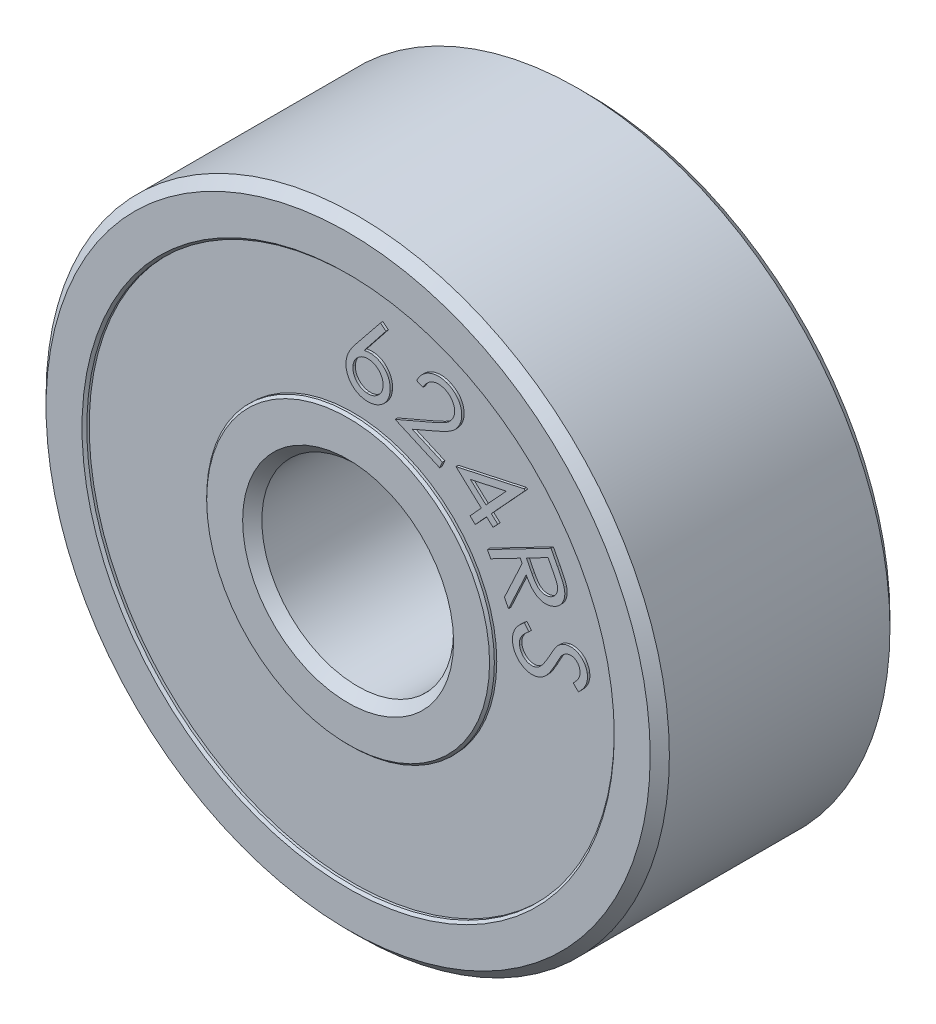
from build123d import *

# Parameters (mm, degrees)
SKETCH1_R           = 6.5
SKETCH1_R_2         = 2
BOSS_EXTRUDE1_DEPTH = 5
SKETCH2_R           = 5.5
SKETCH2_R_2         = 3
CUT_EXTRUDE1_DEPTH  = 0.1
CUT_EXTRUDE2_START  = -4.9
SKETCH2_2_R         = 5.5
SKETCH2_2_R_2       = 3
CUT_EXTRUDE2_DEPTH  = 0.1
CHAMFER1_SIZE       = 0.2
CHAMFER2_SIZE       = 0.05
BOSS_EXTRUDE2_DEPTH = 0.05
BOSS_EXTRUDE3_DEPTH = 0.05


with BuildPart() as part:
    # Sketch1 → Boss-Extrude1 (new body)
    with BuildSketch(Plane.XY):
        Circle(SKETCH1_R)
        Circle(SKETCH1_R_2, mode=Mode.SUBTRACT)
    extrude(amount=BOSS_EXTRUDE1_DEPTH)

    # Sketch2 → Cut-Extrude1 (cut)
    with BuildSketch(Plane.XY.offset(5)):
        Circle(SKETCH2_R)
        Circle(SKETCH2_R_2, mode=Mode.SUBTRACT)
    extrude(amount=-CUT_EXTRUDE1_DEPTH, mode=Mode.SUBTRACT)

    # Sketch2_2 → Cut-Extrude2 (cut)
    with BuildSketch(Plane.XY.offset(5).offset(CUT_EXTRUDE2_START)):
        Circle(SKETCH2_2_R)
        Circle(SKETCH2_2_R_2, mode=Mode.SUBTRACT)
    extrude(amount=-CUT_EXTRUDE2_DEPTH, mode=Mode.SUBTRACT)

    # Chamfer1
    chamfer1_edges = [part.edges().sort_by_distance(p)[0] for p in [
        (-2, 0, 0),
        (-2, 0, 5),
        (-6.5, 0, 5),
        (-6.5, 0, 0),
    ]]
    chamfer(chamfer1_edges, length=CHAMFER1_SIZE)

    # Chamfer2
    chamfer2_edges = [part.edges().sort_by_distance(p)[0] for p in [
        (-3, 0, 5),
        (-5.5, 0, 5),
        (-5.5, 0, 0),
        (-3, 0, 0),
    ]]
    chamfer(chamfer2_edges, length=CHAMFER2_SIZE)

    # Sketch3 → Boss-Extrude2 (add)
    # profile 1 of 5: a face of its own
    with BuildSketch(Plane(origin=(0, 0, 0.1), x_dir=(-1, 0, 0), z_dir=(0, 0, -1))):
        with BuildLine():
            Line((3.626850401, 1.037824219), (3.721802324, 0.923942007))
            add(Edge.make_bspline(
                [(3.721802324, 0.923942007), (3.704208047, 0.910028509), (3.670492204, 0.883366129), (3.626324449, 0.840217202), (3.589323839, 0.797503445), (3.560337169, 0.754296194), (3.539224488, 0.71072062), (3.525914966, 0.66695975), (3.520716042, 0.62289401), (3.523565615, 0.594005214), (3.52498742, 0.579591045)],
                knots=[0, 0, 0, 0, 1.291613416, 2.475113613, 3.551739568, 4.542488394, 5.463974027, 6.331243527, 7.167368001, 8, 8, 8, 8], degree=3))
            add(Edge.make_bspline(
                [(3.52498742, 0.579591045), (3.527274467, 0.567390948), (3.531811528, 0.543188293), (3.544150394, 0.508546185), (3.560175974, 0.475542158), (3.580479348, 0.4451073), (3.603721013, 0.41729304), (3.630069864, 0.393834227), (3.658483943, 0.374176738), (3.689267609, 0.359680955), (3.721038495, 0.349052168), (3.753486298, 0.342999974), (3.786173736, 0.341340247), (3.807754072, 0.343722843), (3.818557132, 0.344915565)],
                knots=[0, 0, 0, 0, 1.068019873, 2.118746719, 3.156924569, 4.22201185, 5.262876175, 6.271215077, 7.252568238, 8.229090771, 9.192407108, 10.131769843, 11.064768797, 12, 12, 12, 12], degree=3))
            add(Edge.make_bspline(
                [(3.818557132, 0.344915565), (3.830901192, 0.347505041), (3.855746676, 0.352717006), (3.891314688, 0.368356986), (3.925499258, 0.38991091), (3.945921844, 0.408384053), (3.956477805, 0.417932392)],
                knots=[0, 0, 0, 0, 0.95294517, 1.918038666, 2.923882512, 4, 4, 4, 4], degree=3))
            add(Edge.make_bspline(
                [(3.956477805, 0.417932392), (3.96396901, 0.42557015), (3.979715441, 0.441624635), (4.002763782, 0.46835635), (4.026262622, 0.499137625), (4.050815029, 0.533381446), (4.075608975, 0.571800714), (4.101571299, 0.613547586), (4.127990018, 0.659263107), (4.14526443, 0.691323333), (4.154194151, 0.707896334)],
                knots=[0, 0, 0, 0, 0.728914955, 1.532171184, 2.403181096, 3.367209391, 4.402740162, 5.518377551, 6.717166475, 8, 8, 8, 8], degree=3))
            add(Edge.make_bspline(
                [(4.154194151, 0.707896334), (4.163188053, 0.724333743), (4.180339931, 0.755680808), (4.205183277, 0.800326292), (4.228651377, 0.840089054), (4.250533454, 0.87506404), (4.270289635, 0.905543505), (4.288243335, 0.93124411), (4.304685043, 0.95214504), (4.315683887, 0.963966008), (4.320660497, 0.969314603)],
                knots=[0, 0, 0, 0, 1.447593943, 2.760643181, 3.947082127, 5.014218628, 5.947845825, 6.752948938, 7.435750889, 8, 8, 8, 8], degree=3))
            add(Edge.make_bspline(
                [(4.320660497, 0.969314603), (4.328342461, 0.976970428), (4.343541921, 0.992118171), (4.368296868, 1.012029814), (4.393624244, 1.030086341), (4.420082765, 1.04525028), (4.447314605, 1.058460667), (4.475594522, 1.068701873), (4.504580443, 1.077575354), (4.524536377, 1.080912491), (4.534602805, 1.082595853)],
                knots=[0, 0, 0, 0, 1.055305512, 2.088017491, 3.089115952, 4.081051721, 5.053816907, 6.032042178, 7.007297443, 8, 8, 8, 8], degree=3))
            add(Edge.make_bspline(
                [(4.534602805, 1.082595853), (4.550402757, 1.084550351), (4.581644836, 1.088415083), (4.628484312, 1.086279171), (4.674049258, 1.078488802), (4.717906567, 1.064618063), (4.759604458, 1.045154564), (4.797896183, 1.019643008), (4.832893224, 0.989029216), (4.863513733, 0.953162606), (4.890374838, 0.913853872), (4.911400466, 0.8708634), (4.927772857, 0.825463607), (4.93367271, 0.793644055), (4.936646074, 0.777607872)],
                knots=[0, 0, 0, 0, 1.016487535, 2.009954501, 2.98497969, 3.965375109, 4.942354616, 5.917569104, 6.897838995, 7.905836826, 8.925467148, 9.933688772, 10.958635713, 12, 12, 12, 12], degree=3))
            add(Edge.make_bspline(
                [(4.936646074, 0.777607872), (4.938745145, 0.760307074), (4.942899861, 0.726063392), (4.94038587, 0.674369559), (4.931596212, 0.623526083), (4.918923549, 0.581615452), (4.90452972, 0.548351297), (4.891348138, 0.522292537), (4.874827075, 0.495976016), (4.856211509, 0.468518378), (4.834876675, 0.440313893), (4.810663255, 0.411473469), (4.784025086, 0.381689122), (4.764756891, 0.362161898), (4.754855209, 0.352127103)],
                knots=[0, 0, 0, 0, 1.298172415, 2.569488581, 3.843349313, 5.140919487, 5.823780046, 6.545592135, 7.317055645, 8.139824152, 9.020030671, 9.953761475, 10.948463845, 12, 12, 12, 12], degree=3))
            Line((4.754855209, 0.352127103), (4.644578767, 0.458797776))
            add(Edge.make_bspline(
                [(4.644578767, 0.458797776), (4.652423272, 0.466980433), (4.667480831, 0.482687074), (4.68871904, 0.505860514), (4.707416905, 0.528159447), (4.723755999, 0.54945041), (4.738497611, 0.569218807), (4.750402887, 0.588230955), (4.760518514, 0.605848689), (4.770471755, 0.627965505), (4.779563284, 0.655246209), (4.786025695, 0.688669116), (4.787621005, 0.72280458), (4.785012981, 0.745473919), (4.783701363, 0.756874699)],
                knots=[0, 0, 0, 0, 1.190021039, 2.284249879, 3.299380519, 4.243752491, 5.101878558, 5.886576637, 6.597417, 7.232690022, 8.429751571, 9.607303489, 10.796673964, 12, 12, 12, 12], degree=3))
            add(Edge.make_bspline(
                [(4.783701363, 0.756874699), (4.780790689, 0.771037388), (4.775147565, 0.798495571), (4.758763995, 0.836272684), (4.735942546, 0.868786436), (4.70739512, 0.895268786), (4.675048626, 0.915867872), (4.639883175, 0.929145577), (4.602398705, 0.934463583), (4.577266497, 0.932078712), (4.564350401, 0.930853065)],
                knots=[0, 0, 0, 0, 1.108515008, 2.149154594, 3.137536709, 4.139157538, 5.121139763, 6.065818199, 7.00597361, 8, 8, 8, 8], degree=3))
            add(Edge.make_bspline(
                [(4.564350401, 0.930853065), (4.556406427, 0.929287432), (4.540533699, 0.926159167), (4.517258996, 0.918995167), (4.494965958, 0.908933092), (4.473158044, 0.896352389), (4.451485284, 0.880569468), (4.430101671, 0.860157962), (4.407866409, 0.836049003), (4.394014465, 0.817606628), (4.386766267, 0.80795643)],
                knots=[0, 0, 0, 0, 0.874134105, 1.746593301, 2.623066901, 3.509958883, 4.461948442, 5.510563495, 6.697371876, 8, 8, 8, 8], degree=3))
            add(Edge.make_bspline(
                [(4.386766267, 0.80795643), (4.384448351, 0.804359638), (4.378892164, 0.795737906), (4.369631506, 0.780434278), (4.358254347, 0.760574245), (4.344719246, 0.736085281), (4.328836024, 0.707069489), (4.310831024, 0.67340145), (4.290667935, 0.635103289), (4.276485012, 0.608039082), (4.268977805, 0.593713642)],
                knots=[0, 0, 0, 0, 0.419915097, 1.006562311, 1.755152363, 2.665957554, 3.752458516, 5.001381418, 6.412791848, 8, 8, 8, 8], degree=3))
            add(Edge.make_bspline(
                [(4.268977805, 0.593713642), (4.259750587, 0.576537768), (4.241880228, 0.543273241), (4.214444108, 0.495668435), (4.187615596, 0.451829827), (4.160828729, 0.412040216), (4.134393651, 0.376302617), (4.108618802, 0.344245255), (4.083092264, 0.316281264), (4.050350346, 0.284547321), (4.008423038, 0.251820672), (3.956337945, 0.220115028), (3.90216947, 0.197587105), (3.864690469, 0.189801852), (3.846201363, 0.185961238)],
                knots=[0, 0, 0, 0, 1.151152092, 2.229437114, 3.243727275, 4.185219098, 5.060489077, 5.867724371, 6.612822705, 7.294559218, 8.558076777, 9.743697047, 10.88692268, 12, 12, 12, 12], degree=3))
            add(Edge.make_bspline(
                [(3.846201363, 0.185961238), (3.832902235, 0.1842929), (3.806675002, 0.181002767), (3.767368222, 0.180727536), (3.728817328, 0.184744413), (3.690954914, 0.192546062), (3.653721453, 0.204259803), (3.617511074, 0.220474713), (3.581834792, 0.240374163), (3.547442946, 0.264260413), (3.514942702, 0.290955541), (3.485501714, 0.320216244), (3.459929706, 0.351992513), (3.437496942, 0.385840753), (3.418496239, 0.421960086), (3.403268322, 0.460391274), (3.390907294, 0.500845851), (3.385971364, 0.528942883), (3.383460978, 0.543232872)],
                knots=[0, 0, 0, 0, 0.990068758, 1.952516339, 2.897638706, 3.85009734, 4.805371441, 5.776549141, 6.777491295, 7.820689345, 8.867165879, 9.882730625, 10.8828511, 11.876649465, 12.880025309, 13.893212692, 14.928500021, 16, 16, 16, 16], degree=3))
            add(Edge.make_bspline(
                [(3.383460978, 0.543232872), (3.382028253, 0.554336019), (3.379183253, 0.576383834), (3.377250953, 0.609423043), (3.378349551, 0.642053644), (3.381239039, 0.674298362), (3.386637003, 0.706154669), (3.394568519, 0.737431881), (3.404423829, 0.768359028), (3.417144927, 0.798787289), (3.432682671, 0.829076618), (3.450917889, 0.859464578), (3.472692041, 0.889478116), (3.497611153, 0.919272374), (3.525118397, 0.949432653), (3.556295291, 0.979033882), (3.590219737, 1.008882408), (3.614439499, 1.028018391), (3.626850401, 1.037824219)],
                knots=[0, 0, 0, 0, 0.922849125, 1.83252624, 2.724682092, 3.612086693, 4.499913804, 5.385125807, 6.270376324, 7.173621887, 8.100562672, 9.074879717, 10.092398847, 11.153899387, 12.27594983, 13.455648223, 14.696201057, 16, 16, 16, 16], degree=3))
        make_face()
    # profile 2 of 5: a face of its own
    with BuildSketch(Plane(origin=(0, 0, 0.1), x_dir=(-1, 0, 0), z_dir=(0, 0, -1))):
        with BuildLine():
            Line((4.180961253, 2.661278946), (4.317680003, 2.39715635))
            add(Edge.make_bspline(
                [(4.317680003, 2.39715635), (4.326730105, 2.379445993), (4.344075969, 2.345501465), (4.368399928, 2.296512528), (4.390110511, 2.251820334), (4.408867576, 2.211199615), (4.424441647, 2.174700738), (4.437188759, 2.142345167), (4.44726418, 2.114221956), (4.452370529, 2.09659927), (4.454699234, 2.0885626)],
                knots=[0, 0, 0, 0, 1.411609642, 2.705559517, 3.881981435, 4.93806446, 5.880854452, 6.698015115, 7.406241321, 8, 8, 8, 8], degree=3))
            add(Edge.make_bspline(
                [(4.454699234, 2.0885626), (4.457292448, 2.077681836), (4.462419066, 2.056171267), (4.466737762, 2.02356766), (4.4689685, 1.991346561), (4.468483089, 1.959449342), (4.464683721, 1.928019124), (4.458643948, 1.896996184), (4.450400739, 1.866214033), (4.438804867, 1.836271817), (4.42510038, 1.807159306), (4.408908963, 1.779358997), (4.389855052, 1.753486138), (4.368356097, 1.729322828), (4.344501495, 1.706747619), (4.318299113, 1.685569244), (4.28932489, 1.666342938), (4.268687588, 1.655021463), (4.258184811, 1.649259715)],
                knots=[0, 0, 0, 0, 1.026659344, 2.029639397, 3.015988796, 3.991209219, 4.954206164, 5.919353393, 6.892315353, 7.876345846, 8.863852656, 9.845127721, 10.825755862, 11.809657368, 12.811666787, 13.83882051, 14.90012814, 16, 16, 16, 16], degree=3))
            add(Edge.make_bspline(
                [(4.258184811, 1.649259715), (4.24037304, 1.640692524), (4.205619079, 1.623976397), (4.150657197, 1.608647322), (4.096043185, 1.599970672), (4.041544476, 1.600590144), (3.988110284, 1.608296973), (3.93676339, 1.625497082), (3.887227343, 1.649554562), (3.8484377, 1.676694945), (3.818818516, 1.702939604), (3.796199441, 1.725580471), (3.773657627, 1.75112009), (3.751556814, 1.779812136), (3.729238607, 1.811141545), (3.707007631, 1.845383024), (3.685168819, 1.882696076), (3.671069901, 1.908733135), (3.663833849, 1.922096254)],
                knots=[0, 0, 0, 0, 1.274152581, 2.48610028, 3.669858885, 4.834212196, 5.992386134, 7.142002376, 8.316517092, 9.538521479, 10.184759645, 10.870850826, 11.604109382, 12.38305036, 13.208694259, 14.087843358, 15.018615107, 16, 16, 16, 16], degree=3))
            Line((3.663833849, 1.922096254), (3.294542984, 1.125822215))
            Line((3.294542984, 1.125822215), (3.209506926, 1.289884715))
            Line((3.209506926, 1.289884715), (3.579398753, 2.085257311))
            Line((3.579398753, 2.085257311), (3.540035772, 2.160978465))
            Line((3.540035772, 2.160978465), (2.923449234, 1.841567408))
            Line((2.923449234, 1.841567408), (2.854939618, 1.974079427))
            Line((2.854939618, 1.974079427), (4.180961253, 2.661278946))
        make_face()
        with BuildLine():
            Line((4.119663176, 2.461459235), (3.668942022, 2.227985677))
            Line((3.668942022, 2.227985677), (3.785528561, 1.999019331))
            add(Edge.make_bspline(
                [(3.785528561, 1.999019331), (3.79104016, 1.988348873), (3.801701132, 1.967709227), (3.818731749, 1.93867347), (3.834861995, 1.91180126), (3.85070954, 1.887483445), (3.866287278, 1.865769519), (3.881700667, 1.846766768), (3.896583313, 1.830138433), (3.916097035, 1.811881354), (3.941244444, 1.792901081), (3.973631669, 1.77547882), (4.008226988, 1.764018643), (4.044171118, 1.757728549), (4.080839517, 1.756818273), (4.117189102, 1.761366688), (4.152853177, 1.771335374), (4.175281902, 1.781844327), (4.186670388, 1.787180388)],
                knots=[0, 0, 0, 0, 1.114280803, 2.155330296, 3.122918535, 4.022635355, 4.84813995, 5.601528003, 6.292407311, 6.917092328, 8.078931613, 9.205779165, 10.313879082, 11.446195037, 12.580492965, 13.704538699, 14.834448759, 16, 16, 16, 16], degree=3))
            add(Edge.make_bspline(
                [(4.186670388, 1.787180388), (4.197410656, 1.793260137), (4.218506428, 1.805201829), (4.246078832, 1.828688661), (4.270236703, 1.85527157), (4.289725771, 1.885570944), (4.305221402, 1.917803762), (4.315156032, 1.951600957), (4.320210368, 1.98612726), (4.319291018, 2.015687696), (4.315704913, 2.040541887), (4.310749898, 2.061372734), (4.304181315, 2.084288027), (4.295244844, 2.109087609), (4.284463137, 2.135920525), (4.271793487, 2.164907778), (4.256997207, 2.195788901), (4.24630451, 2.216987448), (4.240756926, 2.227985677)],
                knots=[0, 0, 0, 0, 1.166847319, 2.291892849, 3.414053437, 4.558932773, 5.69227133, 6.791120704, 7.883477436, 8.984577924, 9.579066627, 10.260432269, 11.01120924, 11.836540401, 12.756344371, 13.750661558, 14.832998356, 16, 16, 16, 16], degree=3))
            Line((4.240756926, 2.227985677), (4.119663176, 2.461459235))
        make_face(mode=Mode.SUBTRACT)
    # profile 3 of 5: a face of its own
    with BuildSketch(Plane(origin=(0, 0, 0.1), x_dir=(-1, 0, 0), z_dir=(0, 0, -1))):
        Polygon((3.620656665, 3.454290028), (3.643192722, 3.433556855), (2.935560511, 2.663725124), (3.069274453, 2.540828489), (2.971618203, 2.434758778), (2.837904261, 2.557655412), (2.601726376, 2.300744355), (2.491449934, 2.402006374), (2.727627819, 2.658917431), (2.199382626, 3.144494355), align=None)
        Polygon((2.825284069, 2.764987143), (3.248360992, 3.225323681), (2.499863396, 3.064265989), align=None, mode=Mode.SUBTRACT)
    # profile 4 of 5: a face of its own
    with BuildSketch(Plane(origin=(0, 0, 0.1), x_dir=(-1, 0, 0), z_dir=(0, 0, -1))):
        with BuildLine():
            Line((1.510050651, 4.230559405), (1.379041036, 4.288552193))
            add(Edge.make_bspline(
                [(1.379041036, 4.288552193), (1.387145817, 4.304751573), (1.403038454, 4.336516879), (1.431770278, 4.380472902), (1.462525906, 4.421004186), (1.496639491, 4.457304062), (1.533939618, 4.48919168), (1.573578888, 4.517667048), (1.61634448, 4.541803151), (1.661436439, 4.561800225), (1.708044153, 4.577321268), (1.755217522, 4.588302684), (1.802537111, 4.594310669), (1.849962332, 4.595608387), (1.897527587, 4.591668369), (1.945017901, 4.582345473), (1.99288951, 4.569111731), (2.023793722, 4.556220626), (2.039497767, 4.549669982)],
                knots=[0, 0, 0, 0, 1.098472811, 2.153991387, 3.18135678, 4.18330354, 5.170313889, 6.155356867, 7.140793633, 8.144969052, 9.144534331, 10.11772753, 11.079789428, 12.034448663, 12.992064255, 13.969651809, 14.968274006, 16, 16, 16, 16], degree=3))
            add(Edge.make_bspline(
                [(2.039497767, 4.549669982), (2.054664818, 4.542532612), (2.084481565, 4.528501331), (2.125913878, 4.503173202), (2.163444062, 4.475104694), (2.197118763, 4.444330016), (2.226654178, 4.410502768), (2.252346266, 4.373947331), (2.274164205, 4.334587086), (2.291637581, 4.292798267), (2.305025994, 4.249795288), (2.314471938, 4.20666378), (2.319599547, 4.163802485), (2.320661184, 4.121107819), (2.316811359, 4.078666212), (2.309425669, 4.036349354), (2.297365149, 3.994361569), (2.286155885, 3.967240818), (2.280483344, 3.953516136)],
                knots=[0, 0, 0, 0, 1.119932071, 2.201662696, 3.239503091, 4.248874078, 5.24534844, 6.235458661, 7.230492249, 8.247738698, 9.257908871, 10.237640673, 11.195225776, 12.139539417, 13.087052323, 14.039285123, 15.007763863, 16, 16, 16, 16], degree=3))
            add(Edge.make_bspline(
                [(2.280483344, 3.953516136), (2.271338959, 3.934721499), (2.253201314, 3.897442837), (2.217732621, 3.846326015), (2.176376664, 3.799964913), (2.136252469, 3.76561335), (2.099838436, 3.739819419), (2.068162238, 3.719364781), (2.032185142, 3.698099084), (1.991692825, 3.676351183), (1.947459883, 3.653017483), (1.898405736, 3.629811507), (1.845466338, 3.605041041), (1.808369677, 3.588940582), (1.789197286, 3.580619501)],
                knots=[0, 0, 0, 0, 1.187291654, 2.354961401, 3.524866138, 4.71241741, 5.349457435, 6.062065615, 6.856333144, 7.725585005, 8.675943624, 9.70017229, 10.811397175, 12, 12, 12, 12], degree=3))
            Line((1.789197286, 3.580619501), (1.286492959, 3.363972866))
            Line((1.286492959, 3.363972866), (1.917502574, 3.084525751))
            Line((1.917502574, 3.084525751), (1.858908824, 2.952614693))
            Line((1.858908824, 2.952614693), (0.930423247, 3.363972866))
            Line((0.930423247, 3.363972866), (1.702658824, 3.696905559))
            add(Edge.make_bspline(
                [(1.702658824, 3.696905559), (1.721408486, 3.704973326), (1.757496432, 3.720501563), (1.809115954, 3.743571519), (1.856019794, 3.765464989), (1.898193145, 3.786211754), (1.935633677, 3.805699075), (1.968658136, 3.823656286), (1.996850094, 3.840678363), (2.027925651, 3.861626316), (2.061198155, 3.8890088), (2.095497083, 3.925372464), (2.124584974, 3.965446575), (2.138970054, 3.994944892), (2.14616844, 4.00970604)],
                knots=[0, 0, 0, 0, 1.320544449, 2.541685241, 3.657762437, 4.66915467, 5.582115856, 6.388369264, 7.100722474, 7.711799849, 8.811962042, 9.880054591, 10.939165689, 12, 12, 12, 12], degree=3))
            add(Edge.make_bspline(
                [(2.14616844, 4.00970604), (2.150075031, 4.019250682), (2.157804836, 4.03813626), (2.165777025, 4.06739065), (2.171077504, 4.09674017), (2.172898925, 4.126392524), (2.171182976, 4.156162786), (2.167111431, 4.186198939), (2.159451919, 4.216385927), (2.14866945, 4.246413225), (2.135360691, 4.27550239), (2.119619448, 4.302980997), (2.101220755, 4.328118933), (2.080716967, 4.351475386), (2.057745813, 4.372624392), (2.032250373, 4.391524275), (2.004701471, 4.408923362), (1.984724783, 4.418175183), (1.974593921, 4.422867097)],
                knots=[0, 0, 0, 0, 0.994116477, 1.967015987, 2.918568873, 3.867272057, 4.82508394, 5.791194184, 6.78718724, 7.823245331, 8.865234072, 9.869581863, 10.872673899, 11.86528656, 12.863667137, 13.87823509, 14.923980369, 16, 16, 16, 16], degree=3))
            add(Edge.make_bspline(
                [(1.974593921, 4.422867097), (1.963761239, 4.427412396), (1.942540929, 4.436316254), (1.909705245, 4.445427858), (1.877296888, 4.452023239), (1.844935144, 4.454638619), (1.812819795, 4.454072188), (1.780803053, 4.450110374), (1.748896153, 4.442863606), (1.717363168, 4.432368455), (1.686630426, 4.418518016), (1.657177024, 4.401327819), (1.629016078, 4.380991319), (1.602104629, 4.357493895), (1.576986426, 4.330312885), (1.553255621, 4.300056952), (1.530425994, 4.266862617), (1.516973555, 4.2428941), (1.510050651, 4.230559405)],
                knots=[0, 0, 0, 0, 1.006777016, 1.972191292, 2.917514719, 3.840113076, 4.751035051, 5.668618705, 6.602431334, 7.553399694, 8.514790995, 9.488883669, 10.473716805, 11.490526269, 12.54829402, 13.643269531, 14.787177658, 16, 16, 16, 16], degree=3))
        make_face()
    # profile 5 of 5: a face of its own
    with BuildSketch(Plane(origin=(0, 0, 0.1), x_dir=(-1, 0, 0), z_dir=(0, 0, -1))):
        with BuildLine():
            Line((0.624776682, 4.952259739), (0.740461778, 4.861514547))
            Line((0.740461778, 4.861514547), (0.28433197, 4.286093874))
            add(Edge.make_bspline(
                [(0.28433197, 4.286093874), (0.297913488, 4.289130482), (0.324512904, 4.295077682), (0.364034896, 4.299862081), (0.402013485, 4.302542442), (0.426660399, 4.300983157), (0.438779086, 4.30021647)],
                knots=[0, 0, 0, 0, 1.071719456, 2.098963569, 3.0652759, 4, 4, 4, 4], degree=3))
            add(Edge.make_bspline(
                [(0.438779086, 4.30021647), (0.453256197, 4.298638554), (0.481875797, 4.295519193), (0.523362149, 4.285244369), (0.563007581, 4.271850387), (0.600495385, 4.254306323), (0.635745366, 4.232807797), (0.66918257, 4.207673802), (0.700317801, 4.17840123), (0.729302223, 4.145835801), (0.755353363, 4.110591735), (0.777621867, 4.073361536), (0.7957566, 4.034576289), (0.810097943, 3.994382393), (0.819864391, 3.952522556), (0.825873487, 3.909184638), (0.828184934, 3.864402237), (0.826201951, 3.83416481), (0.825197355, 3.818846277)],
                knots=[0, 0, 0, 0, 1.015568828, 2.00766382, 2.976145101, 3.933303476, 4.890206439, 5.853702754, 6.848061907, 7.868265483, 8.893321337, 9.902976031, 10.891393065, 11.877681008, 12.876577557, 13.886159619, 14.929110891, 16, 16, 16, 16], degree=3))
            add(Edge.make_bspline(
                [(0.825197355, 3.818846277), (0.822641534, 3.797911902), (0.817611645, 3.756712778), (0.800705633, 3.697411121), (0.776907806, 3.641866185), (0.745772648, 3.590736956), (0.70848601, 3.544158225), (0.664764159, 3.503349438), (0.615397948, 3.468206156), (0.560848705, 3.439630056), (0.502837334, 3.41772126), (0.442575532, 3.403433222), (0.380687083, 3.397213948), (0.339222816, 3.399249006), (0.318286297, 3.400276566)],
                knots=[0, 0, 0, 0, 1.034807193, 2.036514014, 3.017323823, 3.995401927, 4.968304749, 5.93957607, 6.92402046, 7.936534245, 8.956493742, 9.962650391, 10.971282688, 12, 12, 12, 12], degree=3))
            add(Edge.make_bspline(
                [(0.318286297, 3.400276566), (0.298264394, 3.402781974), (0.258618039, 3.407743055), (0.201034749, 3.42391263), (0.146469258, 3.447659939), (0.095270137, 3.478245834), (0.048258044, 3.514977754), (0.007404583, 3.558181271), (-0.027490409, 3.606627502), (-0.055537957, 3.660118708), (-0.076734057, 3.716893341), (-0.09072973, 3.775604202), (-0.097051477, 3.835666265), (-0.095004567, 3.875833348), (-0.093973318, 3.896069835)],
                knots=[0, 0, 0, 0, 1.010456378, 2.000854323, 2.985828397, 3.98554961, 4.982998726, 5.966756315, 6.956084606, 7.966777971, 8.985186711, 9.986256115, 10.985460249, 12, 12, 12, 12], degree=3))
            add(Edge.make_bspline(
                [(-0.093973318, 3.896069835), (-0.092187896, 3.911448661), (-0.088548919, 3.942793182), (-0.07690777, 3.989759936), (-0.061379341, 4.03766137), (-0.044278262, 4.077758906), (-0.028063916, 4.110723925), (-0.013566117, 4.136858278), (0.002936551, 4.164078322), (0.021371761, 4.192370779), (0.041526186, 4.221813105), (0.06348713, 4.25252685), (0.087442418, 4.284361237), (0.104579955, 4.305575652), (0.113358413, 4.316442431)],
                knots=[0, 0, 0, 0, 1.170286953, 2.385232953, 3.652916422, 4.977313568, 5.678831186, 6.431792633, 7.237546989, 8.086710099, 8.986311032, 9.936815019, 10.943163086, 12, 12, 12, 12], degree=3))
            Line((0.113358413, 4.316442431), (0.624776682, 4.952259739))
        make_face()
        with BuildLine():
            add(Edge.make_bspline(
                [(0.391904086, 4.172512143), (0.381289848, 4.173259933), (0.36025591, 4.174741808), (0.329059796, 4.172627268), (0.298744351, 4.168271358), (0.269435442, 4.16068514), (0.241052365, 4.150095585), (0.213613002, 4.136581662), (0.187298044, 4.11974222), (0.162064143, 4.100553065), (0.138752163, 4.078903587), (0.117585431, 4.055880804), (0.09941003, 4.031107994), (0.084383305, 4.004671789), (0.071727571, 3.977047979), (0.061629285, 3.947923081), (0.054765919, 3.917254438), (0.052370145, 3.89619846), (0.051158893, 3.885553008)],
                knots=[0, 0, 0, 0, 1.029253913, 2.039643683, 3.02041037, 3.991973658, 4.964843234, 5.949486958, 6.947793764, 7.985649025, 9.015222788, 10.024541267, 11.010044483, 11.98330077, 12.964211325, 13.948807276, 14.962960842, 16, 16, 16, 16], degree=3))
            add(Edge.make_bspline(
                [(0.051158893, 3.885553008), (0.050411068, 3.874938749), (0.048929125, 3.853904768), (0.051044166, 3.822708968), (0.055398237, 3.79239237), (0.062991229, 3.763087706), (0.073555409, 3.734688729), (0.087141916, 3.707357398), (0.1035767, 3.680852157), (0.122839681, 3.655726379), (0.144463035, 3.632400816), (0.16748402, 3.611222819), (0.192218284, 3.593155175), (0.218448871, 3.577948418), (0.246027645, 3.565379827), (0.274968609, 3.555377379), (0.3053978, 3.548341528), (0.326266926, 3.546001761), (0.336916105, 3.544807816)],
                knots=[0, 0, 0, 0, 1.031346273, 2.043790053, 3.02655053, 4.000088899, 4.974936212, 5.961581607, 6.956758403, 7.996723509, 9.028390282, 10.039760594, 11.027267228, 11.994087766, 12.976992403, 13.96358993, 14.960852656, 16, 16, 16, 16], degree=3))
            add(Edge.make_bspline(
                [(0.336916105, 3.544807816), (0.347530345, 3.544060023), (0.368564287, 3.542578144), (0.399760371, 3.544692715), (0.430075924, 3.549048511), (0.459384436, 3.556635151), (0.487769, 3.567223125), (0.515202721, 3.580743047), (0.541539353, 3.597559442), (0.566747893, 3.61688287), (0.590370743, 3.638212434), (0.611240538, 3.661537793), (0.629277182, 3.686241852), (0.644876654, 3.712308691), (0.657369089, 3.739988762), (0.667397797, 3.76891485), (0.674426595, 3.799348036), (0.676767336, 3.82021661), (0.677961778, 3.830865508)],
                knots=[0, 0, 0, 0, 1.030655014, 2.042420205, 3.024521988, 3.997407844, 4.971601766, 5.957585863, 6.957251642, 7.996519712, 9.03465259, 10.038837507, 11.025682266, 11.996772725, 12.979018571, 13.964954831, 14.961549143, 16, 16, 16, 16], degree=3))
            add(Edge.make_bspline(
                [(0.677961778, 3.830865508), (0.678713604, 3.841580269), (0.680196593, 3.862715322), (0.678050187, 3.894105422), (0.673768398, 3.924535731), (0.666069522, 3.954011623), (0.65562095, 3.982546554), (0.642022121, 4.010054884), (0.625194002, 4.036373107), (0.606003817, 4.061609872), (0.584346724, 4.084907093), (0.56135455, 4.106128415), (0.536499475, 4.124084971), (0.510542248, 4.139802771), (0.482699633, 4.151840823), (0.453866165, 4.161973077), (0.423418549, 4.168970396), (0.402551967, 4.171315483), (0.391904086, 4.172512143)],
                knots=[0, 0, 0, 0, 1.038813289, 2.049077496, 3.039314004, 4.010756555, 4.992599461, 5.977120821, 6.975303566, 8.01302985, 9.042475667, 10.051668716, 11.037049462, 12.006699279, 12.983500288, 13.967973882, 14.963089716, 16, 16, 16, 16], degree=3))
        make_face(mode=Mode.SUBTRACT)
    extrude(amount=BOSS_EXTRUDE2_DEPTH)

    # Sketch4 → Boss-Extrude3 (add)
    # profile 1 of 5: a face of its own
    with BuildSketch(Plane.XY.offset(4.9)):
        with BuildLine():
            Line((3.626850401, 1.037824219), (3.721802324, 0.923942007))
            add(Edge.make_bspline(
                [(3.721802324, 0.923942007), (3.704208047, 0.910028509), (3.670492204, 0.883366129), (3.626324449, 0.840217202), (3.589323839, 0.797503445), (3.560337169, 0.754296194), (3.539224488, 0.71072062), (3.525914966, 0.66695975), (3.520716042, 0.62289401), (3.523565615, 0.594005214), (3.52498742, 0.579591045)],
                knots=[0, 0, 0, 0, 1.291613416, 2.475113613, 3.551739568, 4.542488394, 5.463974027, 6.331243527, 7.167368001, 8, 8, 8, 8], degree=3))
            add(Edge.make_bspline(
                [(3.52498742, 0.579591045), (3.527274467, 0.567390948), (3.531811528, 0.543188293), (3.544150394, 0.508546185), (3.560175974, 0.475542158), (3.580479348, 0.4451073), (3.603721013, 0.41729304), (3.630069864, 0.393834227), (3.658483943, 0.374176738), (3.689267609, 0.359680955), (3.721038495, 0.349052168), (3.753486298, 0.342999974), (3.786173736, 0.341340247), (3.807754072, 0.343722843), (3.818557132, 0.344915565)],
                knots=[0, 0, 0, 0, 1.068019873, 2.118746719, 3.156924569, 4.22201185, 5.262876175, 6.271215077, 7.252568238, 8.229090771, 9.192407108, 10.131769843, 11.064768797, 12, 12, 12, 12], degree=3))
            add(Edge.make_bspline(
                [(3.818557132, 0.344915565), (3.830901192, 0.347505041), (3.855746676, 0.352717006), (3.891314688, 0.368356986), (3.925499258, 0.38991091), (3.945921844, 0.408384053), (3.956477805, 0.417932392)],
                knots=[0, 0, 0, 0, 0.95294517, 1.918038666, 2.923882512, 4, 4, 4, 4], degree=3))
            add(Edge.make_bspline(
                [(3.956477805, 0.417932392), (3.96396901, 0.42557015), (3.979715441, 0.441624635), (4.002763782, 0.46835635), (4.026262622, 0.499137625), (4.050815029, 0.533381446), (4.075608975, 0.571800714), (4.101571299, 0.613547586), (4.127990018, 0.659263107), (4.14526443, 0.691323333), (4.154194151, 0.707896334)],
                knots=[0, 0, 0, 0, 0.728914955, 1.532171184, 2.403181096, 3.367209391, 4.402740162, 5.518377551, 6.717166475, 8, 8, 8, 8], degree=3))
            add(Edge.make_bspline(
                [(4.154194151, 0.707896334), (4.163188053, 0.724333743), (4.180339931, 0.755680808), (4.205183277, 0.800326292), (4.228651377, 0.840089054), (4.250533454, 0.87506404), (4.270289635, 0.905543505), (4.288243335, 0.93124411), (4.304685043, 0.95214504), (4.315683887, 0.963966008), (4.320660497, 0.969314603)],
                knots=[0, 0, 0, 0, 1.447593943, 2.760643181, 3.947082127, 5.014218628, 5.947845825, 6.752948938, 7.435750889, 8, 8, 8, 8], degree=3))
            add(Edge.make_bspline(
                [(4.320660497, 0.969314603), (4.328342461, 0.976970428), (4.343541921, 0.992118171), (4.368296868, 1.012029814), (4.393624244, 1.030086341), (4.420082765, 1.04525028), (4.447314605, 1.058460667), (4.475594522, 1.068701873), (4.504580443, 1.077575354), (4.524536377, 1.080912491), (4.534602805, 1.082595853)],
                knots=[0, 0, 0, 0, 1.055305512, 2.088017491, 3.089115952, 4.081051721, 5.053816907, 6.032042178, 7.007297443, 8, 8, 8, 8], degree=3))
            add(Edge.make_bspline(
                [(4.534602805, 1.082595853), (4.550402757, 1.084550351), (4.581644836, 1.088415083), (4.628484312, 1.086279171), (4.674049258, 1.078488802), (4.717906567, 1.064618063), (4.759604458, 1.045154564), (4.797896183, 1.019643008), (4.832893224, 0.989029216), (4.863513733, 0.953162606), (4.890374838, 0.913853872), (4.911400466, 0.8708634), (4.927772857, 0.825463607), (4.93367271, 0.793644055), (4.936646074, 0.777607872)],
                knots=[0, 0, 0, 0, 1.016487535, 2.009954501, 2.98497969, 3.965375109, 4.942354616, 5.917569104, 6.897838995, 7.905836826, 8.925467148, 9.933688772, 10.958635713, 12, 12, 12, 12], degree=3))
            add(Edge.make_bspline(
                [(4.936646074, 0.777607872), (4.938745145, 0.760307074), (4.942899861, 0.726063392), (4.94038587, 0.674369559), (4.931596212, 0.623526083), (4.918923549, 0.581615452), (4.90452972, 0.548351297), (4.891348138, 0.522292537), (4.874827075, 0.495976016), (4.856211509, 0.468518378), (4.834876675, 0.440313893), (4.810663255, 0.411473469), (4.784025086, 0.381689122), (4.764756891, 0.362161898), (4.754855209, 0.352127103)],
                knots=[0, 0, 0, 0, 1.298172415, 2.569488581, 3.843349313, 5.140919487, 5.823780046, 6.545592135, 7.317055645, 8.139824152, 9.020030671, 9.953761475, 10.948463845, 12, 12, 12, 12], degree=3))
            Line((4.754855209, 0.352127103), (4.644578767, 0.458797776))
            add(Edge.make_bspline(
                [(4.644578767, 0.458797776), (4.652423272, 0.466980433), (4.667480831, 0.482687074), (4.68871904, 0.505860514), (4.707416905, 0.528159447), (4.723755999, 0.54945041), (4.738497611, 0.569218807), (4.750402887, 0.588230955), (4.760518514, 0.605848689), (4.770471755, 0.627965505), (4.779563284, 0.655246209), (4.786025695, 0.688669116), (4.787621005, 0.72280458), (4.785012981, 0.745473919), (4.783701363, 0.756874699)],
                knots=[0, 0, 0, 0, 1.190021039, 2.284249879, 3.299380519, 4.243752491, 5.101878558, 5.886576637, 6.597417, 7.232690022, 8.429751571, 9.607303489, 10.796673964, 12, 12, 12, 12], degree=3))
            add(Edge.make_bspline(
                [(4.783701363, 0.756874699), (4.780790689, 0.771037388), (4.775147565, 0.798495571), (4.758763995, 0.836272684), (4.735942546, 0.868786436), (4.70739512, 0.895268786), (4.675048626, 0.915867872), (4.639883175, 0.929145577), (4.602398705, 0.934463583), (4.577266497, 0.932078712), (4.564350401, 0.930853065)],
                knots=[0, 0, 0, 0, 1.108515008, 2.149154594, 3.137536709, 4.139157538, 5.121139763, 6.065818199, 7.00597361, 8, 8, 8, 8], degree=3))
            add(Edge.make_bspline(
                [(4.564350401, 0.930853065), (4.556406427, 0.929287432), (4.540533699, 0.926159167), (4.517258996, 0.918995167), (4.494965958, 0.908933092), (4.473158044, 0.896352389), (4.451485284, 0.880569468), (4.430101671, 0.860157962), (4.407866409, 0.836049003), (4.394014465, 0.817606628), (4.386766267, 0.80795643)],
                knots=[0, 0, 0, 0, 0.874134105, 1.746593301, 2.623066901, 3.509958883, 4.461948442, 5.510563495, 6.697371876, 8, 8, 8, 8], degree=3))
            add(Edge.make_bspline(
                [(4.386766267, 0.80795643), (4.384448351, 0.804359638), (4.378892164, 0.795737906), (4.369631506, 0.780434278), (4.358254347, 0.760574245), (4.344719246, 0.736085281), (4.328836024, 0.707069489), (4.310831024, 0.67340145), (4.290667935, 0.635103289), (4.276485012, 0.608039082), (4.268977805, 0.593713642)],
                knots=[0, 0, 0, 0, 0.419915097, 1.006562311, 1.755152363, 2.665957554, 3.752458516, 5.001381418, 6.412791848, 8, 8, 8, 8], degree=3))
            add(Edge.make_bspline(
                [(4.268977805, 0.593713642), (4.259750587, 0.576537768), (4.241880228, 0.543273241), (4.214444108, 0.495668435), (4.187615596, 0.451829827), (4.160828729, 0.412040216), (4.134393651, 0.376302617), (4.108618802, 0.344245255), (4.083092264, 0.316281264), (4.050350346, 0.284547321), (4.008423038, 0.251820672), (3.956337945, 0.220115028), (3.90216947, 0.197587105), (3.864690469, 0.189801852), (3.846201363, 0.185961238)],
                knots=[0, 0, 0, 0, 1.151152092, 2.229437114, 3.243727275, 4.185219098, 5.060489077, 5.867724371, 6.612822705, 7.294559218, 8.558076777, 9.743697047, 10.88692268, 12, 12, 12, 12], degree=3))
            add(Edge.make_bspline(
                [(3.846201363, 0.185961238), (3.832902235, 0.1842929), (3.806675002, 0.181002767), (3.767368222, 0.180727536), (3.728817328, 0.184744413), (3.690954914, 0.192546062), (3.653721453, 0.204259803), (3.617511074, 0.220474713), (3.581834792, 0.240374163), (3.547442946, 0.264260413), (3.514942702, 0.290955541), (3.485501714, 0.320216244), (3.459929706, 0.351992513), (3.437496942, 0.385840753), (3.418496239, 0.421960086), (3.403268322, 0.460391274), (3.390907294, 0.500845851), (3.385971364, 0.528942883), (3.383460978, 0.543232872)],
                knots=[0, 0, 0, 0, 0.990068758, 1.952516339, 2.897638706, 3.85009734, 4.805371441, 5.776549141, 6.777491295, 7.820689345, 8.867165879, 9.882730625, 10.8828511, 11.876649465, 12.880025309, 13.893212692, 14.928500021, 16, 16, 16, 16], degree=3))
            add(Edge.make_bspline(
                [(3.383460978, 0.543232872), (3.382028253, 0.554336019), (3.379183253, 0.576383834), (3.377250953, 0.609423043), (3.378349551, 0.642053644), (3.381239039, 0.674298362), (3.386637003, 0.706154669), (3.394568519, 0.737431881), (3.404423829, 0.768359028), (3.417144927, 0.798787289), (3.432682671, 0.829076618), (3.450917889, 0.859464578), (3.472692041, 0.889478116), (3.497611153, 0.919272374), (3.525118397, 0.949432653), (3.556295291, 0.979033882), (3.590219737, 1.008882408), (3.614439499, 1.028018391), (3.626850401, 1.037824219)],
                knots=[0, 0, 0, 0, 0.922849125, 1.83252624, 2.724682092, 3.612086693, 4.499913804, 5.385125807, 6.270376324, 7.173621887, 8.100562672, 9.074879717, 10.092398847, 11.153899387, 12.27594983, 13.455648223, 14.696201057, 16, 16, 16, 16], degree=3))
        make_face()
    # profile 2 of 5: a face of its own
    with BuildSketch(Plane.XY.offset(4.9)):
        with BuildLine():
            Line((4.180961253, 2.661278946), (4.317680003, 2.39715635))
            add(Edge.make_bspline(
                [(4.317680003, 2.39715635), (4.326730105, 2.379445993), (4.344075969, 2.345501465), (4.368399928, 2.296512528), (4.390110511, 2.251820334), (4.408867576, 2.211199615), (4.424441647, 2.174700738), (4.437188759, 2.142345167), (4.44726418, 2.114221956), (4.452370529, 2.09659927), (4.454699234, 2.0885626)],
                knots=[0, 0, 0, 0, 1.411609642, 2.705559517, 3.881981435, 4.93806446, 5.880854452, 6.698015115, 7.406241321, 8, 8, 8, 8], degree=3))
            add(Edge.make_bspline(
                [(4.454699234, 2.0885626), (4.457292448, 2.077681836), (4.462419066, 2.056171267), (4.466737762, 2.02356766), (4.4689685, 1.991346561), (4.468483089, 1.959449342), (4.464683721, 1.928019124), (4.458643948, 1.896996184), (4.450400739, 1.866214033), (4.438804867, 1.836271817), (4.42510038, 1.807159306), (4.408908963, 1.779358997), (4.389855052, 1.753486138), (4.368356097, 1.729322828), (4.344501495, 1.706747619), (4.318299113, 1.685569244), (4.28932489, 1.666342938), (4.268687588, 1.655021463), (4.258184811, 1.649259715)],
                knots=[0, 0, 0, 0, 1.026659344, 2.029639397, 3.015988796, 3.991209219, 4.954206164, 5.919353393, 6.892315353, 7.876345846, 8.863852656, 9.845127721, 10.825755862, 11.809657368, 12.811666787, 13.83882051, 14.90012814, 16, 16, 16, 16], degree=3))
            add(Edge.make_bspline(
                [(4.258184811, 1.649259715), (4.24037304, 1.640692524), (4.205619079, 1.623976397), (4.150657197, 1.608647322), (4.096043185, 1.599970672), (4.041544476, 1.600590144), (3.988110284, 1.608296973), (3.93676339, 1.625497082), (3.887227343, 1.649554562), (3.8484377, 1.676694945), (3.818818516, 1.702939604), (3.796199441, 1.725580471), (3.773657627, 1.75112009), (3.751556814, 1.779812136), (3.729238607, 1.811141545), (3.707007631, 1.845383024), (3.685168819, 1.882696076), (3.671069901, 1.908733135), (3.663833849, 1.922096254)],
                knots=[0, 0, 0, 0, 1.274152581, 2.48610028, 3.669858885, 4.834212196, 5.992386134, 7.142002376, 8.316517092, 9.538521479, 10.184759645, 10.870850826, 11.604109382, 12.38305036, 13.208694259, 14.087843358, 15.018615107, 16, 16, 16, 16], degree=3))
            Line((3.663833849, 1.922096254), (3.294542984, 1.125822215))
            Line((3.294542984, 1.125822215), (3.209506926, 1.289884715))
            Line((3.209506926, 1.289884715), (3.579398753, 2.085257311))
            Line((3.579398753, 2.085257311), (3.540035772, 2.160978465))
            Line((3.540035772, 2.160978465), (2.923449234, 1.841567408))
            Line((2.923449234, 1.841567408), (2.854939618, 1.974079427))
            Line((2.854939618, 1.974079427), (4.180961253, 2.661278946))
        make_face()
        with BuildLine():
            Line((4.119663176, 2.461459235), (3.668942022, 2.227985677))
            Line((3.668942022, 2.227985677), (3.785528561, 1.999019331))
            add(Edge.make_bspline(
                [(3.785528561, 1.999019331), (3.79104016, 1.988348873), (3.801701132, 1.967709227), (3.818731749, 1.93867347), (3.834861995, 1.91180126), (3.85070954, 1.887483445), (3.866287278, 1.865769519), (3.881700667, 1.846766768), (3.896583313, 1.830138433), (3.916097035, 1.811881354), (3.941244444, 1.792901081), (3.973631669, 1.77547882), (4.008226988, 1.764018643), (4.044171118, 1.757728549), (4.080839517, 1.756818273), (4.117189102, 1.761366688), (4.152853177, 1.771335374), (4.175281902, 1.781844327), (4.186670388, 1.787180388)],
                knots=[0, 0, 0, 0, 1.114280803, 2.155330296, 3.122918535, 4.022635355, 4.84813995, 5.601528003, 6.292407311, 6.917092328, 8.078931613, 9.205779165, 10.313879082, 11.446195037, 12.580492965, 13.704538699, 14.834448759, 16, 16, 16, 16], degree=3))
            add(Edge.make_bspline(
                [(4.186670388, 1.787180388), (4.197410656, 1.793260137), (4.218506428, 1.805201829), (4.246078832, 1.828688661), (4.270236703, 1.85527157), (4.289725771, 1.885570944), (4.305221402, 1.917803762), (4.315156032, 1.951600957), (4.320210368, 1.98612726), (4.319291018, 2.015687696), (4.315704913, 2.040541887), (4.310749898, 2.061372734), (4.304181315, 2.084288027), (4.295244844, 2.109087609), (4.284463137, 2.135920525), (4.271793487, 2.164907778), (4.256997207, 2.195788901), (4.24630451, 2.216987448), (4.240756926, 2.227985677)],
                knots=[0, 0, 0, 0, 1.166847319, 2.291892849, 3.414053437, 4.558932773, 5.69227133, 6.791120704, 7.883477436, 8.984577924, 9.579066627, 10.260432269, 11.01120924, 11.836540401, 12.756344371, 13.750661558, 14.832998356, 16, 16, 16, 16], degree=3))
            Line((4.240756926, 2.227985677), (4.119663176, 2.461459235))
        make_face(mode=Mode.SUBTRACT)
    # profile 3 of 5: a face of its own
    with BuildSketch(Plane.XY.offset(4.9)):
        Polygon((3.620656665, 3.454290028), (3.643192722, 3.433556855), (2.935560511, 2.663725124), (3.069274453, 2.540828489), (2.971618203, 2.434758778), (2.837904261, 2.557655412), (2.601726376, 2.300744355), (2.491449934, 2.402006374), (2.727627819, 2.658917431), (2.199382626, 3.144494355), align=None)
        Polygon((2.825284069, 2.764987143), (3.248360992, 3.225323681), (2.499863396, 3.064265989), align=None, mode=Mode.SUBTRACT)
    # profile 4 of 5: a face of its own
    with BuildSketch(Plane.XY.offset(4.9)):
        with BuildLine():
            Line((1.510050651, 4.230559405), (1.379041036, 4.288552193))
            add(Edge.make_bspline(
                [(1.379041036, 4.288552193), (1.387145817, 4.304751573), (1.403038454, 4.336516879), (1.431770278, 4.380472902), (1.462525906, 4.421004186), (1.496639491, 4.457304062), (1.533939618, 4.48919168), (1.573578888, 4.517667048), (1.61634448, 4.541803151), (1.661436439, 4.561800225), (1.708044153, 4.577321268), (1.755217522, 4.588302684), (1.802537111, 4.594310669), (1.849962332, 4.595608387), (1.897527587, 4.591668369), (1.945017901, 4.582345473), (1.99288951, 4.569111731), (2.023793722, 4.556220626), (2.039497767, 4.549669982)],
                knots=[0, 0, 0, 0, 1.098472811, 2.153991387, 3.18135678, 4.18330354, 5.170313889, 6.155356867, 7.140793633, 8.144969052, 9.144534331, 10.11772753, 11.079789428, 12.034448663, 12.992064255, 13.969651809, 14.968274006, 16, 16, 16, 16], degree=3))
            add(Edge.make_bspline(
                [(2.039497767, 4.549669982), (2.054664818, 4.542532612), (2.084481565, 4.528501331), (2.125913878, 4.503173202), (2.163444062, 4.475104694), (2.197118763, 4.444330016), (2.226654178, 4.410502768), (2.252346266, 4.373947331), (2.274164205, 4.334587086), (2.291637581, 4.292798267), (2.305025994, 4.249795288), (2.314471938, 4.20666378), (2.319599547, 4.163802485), (2.320661184, 4.121107819), (2.316811359, 4.078666212), (2.309425669, 4.036349354), (2.297365149, 3.994361569), (2.286155885, 3.967240818), (2.280483344, 3.953516136)],
                knots=[0, 0, 0, 0, 1.119932071, 2.201662696, 3.239503091, 4.248874078, 5.24534844, 6.235458661, 7.230492249, 8.247738698, 9.257908871, 10.237640673, 11.195225776, 12.139539417, 13.087052323, 14.039285123, 15.007763863, 16, 16, 16, 16], degree=3))
            add(Edge.make_bspline(
                [(2.280483344, 3.953516136), (2.271338959, 3.934721499), (2.253201314, 3.897442837), (2.217732621, 3.846326015), (2.176376664, 3.799964913), (2.136252469, 3.76561335), (2.099838436, 3.739819419), (2.068162238, 3.719364781), (2.032185142, 3.698099084), (1.991692825, 3.676351183), (1.947459883, 3.653017483), (1.898405736, 3.629811507), (1.845466338, 3.605041041), (1.808369677, 3.588940582), (1.789197286, 3.580619501)],
                knots=[0, 0, 0, 0, 1.187291654, 2.354961401, 3.524866138, 4.71241741, 5.349457435, 6.062065615, 6.856333144, 7.725585005, 8.675943624, 9.70017229, 10.811397175, 12, 12, 12, 12], degree=3))
            Line((1.789197286, 3.580619501), (1.286492959, 3.363972866))
            Line((1.286492959, 3.363972866), (1.917502574, 3.084525751))
            Line((1.917502574, 3.084525751), (1.858908824, 2.952614693))
            Line((1.858908824, 2.952614693), (0.930423247, 3.363972866))
            Line((0.930423247, 3.363972866), (1.702658824, 3.696905559))
            add(Edge.make_bspline(
                [(1.702658824, 3.696905559), (1.721408486, 3.704973326), (1.757496432, 3.720501563), (1.809115954, 3.743571519), (1.856019794, 3.765464989), (1.898193145, 3.786211754), (1.935633677, 3.805699075), (1.968658136, 3.823656286), (1.996850094, 3.840678363), (2.027925651, 3.861626316), (2.061198155, 3.8890088), (2.095497083, 3.925372464), (2.124584974, 3.965446575), (2.138970054, 3.994944892), (2.14616844, 4.00970604)],
                knots=[0, 0, 0, 0, 1.320544449, 2.541685241, 3.657762437, 4.66915467, 5.582115856, 6.388369264, 7.100722474, 7.711799849, 8.811962042, 9.880054591, 10.939165689, 12, 12, 12, 12], degree=3))
            add(Edge.make_bspline(
                [(2.14616844, 4.00970604), (2.150075031, 4.019250682), (2.157804836, 4.03813626), (2.165777025, 4.06739065), (2.171077504, 4.09674017), (2.172898925, 4.126392524), (2.171182976, 4.156162786), (2.167111431, 4.186198939), (2.159451919, 4.216385927), (2.14866945, 4.246413225), (2.135360691, 4.27550239), (2.119619448, 4.302980997), (2.101220755, 4.328118933), (2.080716967, 4.351475386), (2.057745813, 4.372624392), (2.032250373, 4.391524275), (2.004701471, 4.408923362), (1.984724783, 4.418175183), (1.974593921, 4.422867097)],
                knots=[0, 0, 0, 0, 0.994116477, 1.967015987, 2.918568873, 3.867272057, 4.82508394, 5.791194184, 6.78718724, 7.823245331, 8.865234072, 9.869581863, 10.872673899, 11.86528656, 12.863667137, 13.87823509, 14.923980369, 16, 16, 16, 16], degree=3))
            add(Edge.make_bspline(
                [(1.974593921, 4.422867097), (1.963761239, 4.427412396), (1.942540929, 4.436316254), (1.909705245, 4.445427858), (1.877296888, 4.452023239), (1.844935144, 4.454638619), (1.812819795, 4.454072188), (1.780803053, 4.450110374), (1.748896153, 4.442863606), (1.717363168, 4.432368455), (1.686630426, 4.418518016), (1.657177024, 4.401327819), (1.629016078, 4.380991319), (1.602104629, 4.357493895), (1.576986426, 4.330312885), (1.553255621, 4.300056952), (1.530425994, 4.266862617), (1.516973555, 4.2428941), (1.510050651, 4.230559405)],
                knots=[0, 0, 0, 0, 1.006777016, 1.972191292, 2.917514719, 3.840113076, 4.751035051, 5.668618705, 6.602431334, 7.553399694, 8.514790995, 9.488883669, 10.473716805, 11.490526269, 12.54829402, 13.643269531, 14.787177658, 16, 16, 16, 16], degree=3))
        make_face()
    # profile 5 of 5: a face of its own
    with BuildSketch(Plane.XY.offset(4.9)):
        with BuildLine():
            Line((0.624776682, 4.952259739), (0.740461778, 4.861514547))
            Line((0.740461778, 4.861514547), (0.28433197, 4.286093874))
            add(Edge.make_bspline(
                [(0.28433197, 4.286093874), (0.297913488, 4.289130482), (0.324512904, 4.295077682), (0.364034896, 4.299862081), (0.402013485, 4.302542442), (0.426660399, 4.300983157), (0.438779086, 4.30021647)],
                knots=[0, 0, 0, 0, 1.071719456, 2.098963569, 3.0652759, 4, 4, 4, 4], degree=3))
            add(Edge.make_bspline(
                [(0.438779086, 4.30021647), (0.453256197, 4.298638554), (0.481875797, 4.295519193), (0.523362149, 4.285244369), (0.563007581, 4.271850387), (0.600495385, 4.254306323), (0.635745366, 4.232807797), (0.66918257, 4.207673802), (0.700317801, 4.17840123), (0.729302223, 4.145835801), (0.755353363, 4.110591735), (0.777621867, 4.073361536), (0.7957566, 4.034576289), (0.810097943, 3.994382393), (0.819864391, 3.952522556), (0.825873487, 3.909184638), (0.828184934, 3.864402237), (0.826201951, 3.83416481), (0.825197355, 3.818846277)],
                knots=[0, 0, 0, 0, 1.015568828, 2.00766382, 2.976145101, 3.933303476, 4.890206439, 5.853702754, 6.848061907, 7.868265483, 8.893321337, 9.902976031, 10.891393065, 11.877681008, 12.876577557, 13.886159619, 14.929110891, 16, 16, 16, 16], degree=3))
            add(Edge.make_bspline(
                [(0.825197355, 3.818846277), (0.822641534, 3.797911902), (0.817611645, 3.756712778), (0.800705633, 3.697411121), (0.776907806, 3.641866185), (0.745772648, 3.590736956), (0.70848601, 3.544158225), (0.664764159, 3.503349438), (0.615397948, 3.468206156), (0.560848705, 3.439630056), (0.502837334, 3.41772126), (0.442575532, 3.403433222), (0.380687083, 3.397213948), (0.339222816, 3.399249006), (0.318286297, 3.400276566)],
                knots=[0, 0, 0, 0, 1.034807193, 2.036514014, 3.017323823, 3.995401927, 4.968304749, 5.93957607, 6.92402046, 7.936534245, 8.956493742, 9.962650391, 10.971282688, 12, 12, 12, 12], degree=3))
            add(Edge.make_bspline(
                [(0.318286297, 3.400276566), (0.298264394, 3.402781974), (0.258618039, 3.407743055), (0.201034749, 3.42391263), (0.146469258, 3.447659939), (0.095270137, 3.478245834), (0.048258044, 3.514977754), (0.007404583, 3.558181271), (-0.027490409, 3.606627502), (-0.055537957, 3.660118708), (-0.076734057, 3.716893341), (-0.09072973, 3.775604202), (-0.097051477, 3.835666265), (-0.095004567, 3.875833348), (-0.093973318, 3.896069835)],
                knots=[0, 0, 0, 0, 1.010456378, 2.000854323, 2.985828397, 3.98554961, 4.982998726, 5.966756315, 6.956084606, 7.966777971, 8.985186711, 9.986256115, 10.985460249, 12, 12, 12, 12], degree=3))
            add(Edge.make_bspline(
                [(-0.093973318, 3.896069835), (-0.092187896, 3.911448661), (-0.088548919, 3.942793182), (-0.07690777, 3.989759936), (-0.061379341, 4.03766137), (-0.044278262, 4.077758906), (-0.028063916, 4.110723925), (-0.013566117, 4.136858278), (0.002936551, 4.164078322), (0.021371761, 4.192370779), (0.041526186, 4.221813105), (0.06348713, 4.25252685), (0.087442418, 4.284361237), (0.104579955, 4.305575652), (0.113358413, 4.316442431)],
                knots=[0, 0, 0, 0, 1.170286953, 2.385232953, 3.652916422, 4.977313568, 5.678831186, 6.431792633, 7.237546989, 8.086710099, 8.986311032, 9.936815019, 10.943163086, 12, 12, 12, 12], degree=3))
            Line((0.113358413, 4.316442431), (0.624776682, 4.952259739))
        make_face()
        with BuildLine():
            add(Edge.make_bspline(
                [(0.391904086, 4.172512143), (0.381289848, 4.173259933), (0.36025591, 4.174741808), (0.329059796, 4.172627268), (0.298744351, 4.168271358), (0.269435442, 4.16068514), (0.241052365, 4.150095585), (0.213613002, 4.136581662), (0.187298044, 4.11974222), (0.162064143, 4.100553065), (0.138752163, 4.078903587), (0.117585431, 4.055880804), (0.09941003, 4.031107994), (0.084383305, 4.004671789), (0.071727571, 3.977047979), (0.061629285, 3.947923081), (0.054765919, 3.917254438), (0.052370145, 3.89619846), (0.051158893, 3.885553008)],
                knots=[0, 0, 0, 0, 1.029253913, 2.039643683, 3.02041037, 3.991973658, 4.964843234, 5.949486958, 6.947793764, 7.985649025, 9.015222788, 10.024541267, 11.010044483, 11.98330077, 12.964211325, 13.948807276, 14.962960842, 16, 16, 16, 16], degree=3))
            add(Edge.make_bspline(
                [(0.051158893, 3.885553008), (0.050411068, 3.874938749), (0.048929125, 3.853904768), (0.051044166, 3.822708968), (0.055398237, 3.79239237), (0.062991229, 3.763087706), (0.073555409, 3.734688729), (0.087141916, 3.707357398), (0.1035767, 3.680852157), (0.122839681, 3.655726379), (0.144463035, 3.632400816), (0.16748402, 3.611222819), (0.192218284, 3.593155175), (0.218448871, 3.577948418), (0.246027645, 3.565379827), (0.274968609, 3.555377379), (0.3053978, 3.548341528), (0.326266926, 3.546001761), (0.336916105, 3.544807816)],
                knots=[0, 0, 0, 0, 1.031346273, 2.043790053, 3.02655053, 4.000088899, 4.974936212, 5.961581607, 6.956758403, 7.996723509, 9.028390282, 10.039760594, 11.027267228, 11.994087766, 12.976992403, 13.96358993, 14.960852656, 16, 16, 16, 16], degree=3))
            add(Edge.make_bspline(
                [(0.336916105, 3.544807816), (0.347530345, 3.544060023), (0.368564287, 3.542578144), (0.399760371, 3.544692715), (0.430075924, 3.549048511), (0.459384436, 3.556635151), (0.487769, 3.567223125), (0.515202721, 3.580743047), (0.541539353, 3.597559442), (0.566747893, 3.61688287), (0.590370743, 3.638212434), (0.611240538, 3.661537793), (0.629277182, 3.686241852), (0.644876654, 3.712308691), (0.657369089, 3.739988762), (0.667397797, 3.76891485), (0.674426595, 3.799348036), (0.676767336, 3.82021661), (0.677961778, 3.830865508)],
                knots=[0, 0, 0, 0, 1.030655014, 2.042420205, 3.024521988, 3.997407844, 4.971601766, 5.957585863, 6.957251642, 7.996519712, 9.03465259, 10.038837507, 11.025682266, 11.996772725, 12.979018571, 13.964954831, 14.961549143, 16, 16, 16, 16], degree=3))
            add(Edge.make_bspline(
                [(0.677961778, 3.830865508), (0.678713604, 3.841580269), (0.680196593, 3.862715322), (0.678050187, 3.894105422), (0.673768398, 3.924535731), (0.666069522, 3.954011623), (0.65562095, 3.982546554), (0.642022121, 4.010054884), (0.625194002, 4.036373107), (0.606003817, 4.061609872), (0.584346724, 4.084907093), (0.56135455, 4.106128415), (0.536499475, 4.124084971), (0.510542248, 4.139802771), (0.482699633, 4.151840823), (0.453866165, 4.161973077), (0.423418549, 4.168970396), (0.402551967, 4.171315483), (0.391904086, 4.172512143)],
                knots=[0, 0, 0, 0, 1.038813289, 2.049077496, 3.039314004, 4.010756555, 4.992599461, 5.977120821, 6.975303566, 8.01302985, 9.042475667, 10.051668716, 11.037049462, 12.006699279, 12.983500288, 13.967973882, 14.963089716, 16, 16, 16, 16], degree=3))
        make_face(mode=Mode.SUBTRACT)
    extrude(amount=BOSS_EXTRUDE3_DEPTH)


solid = part.part
